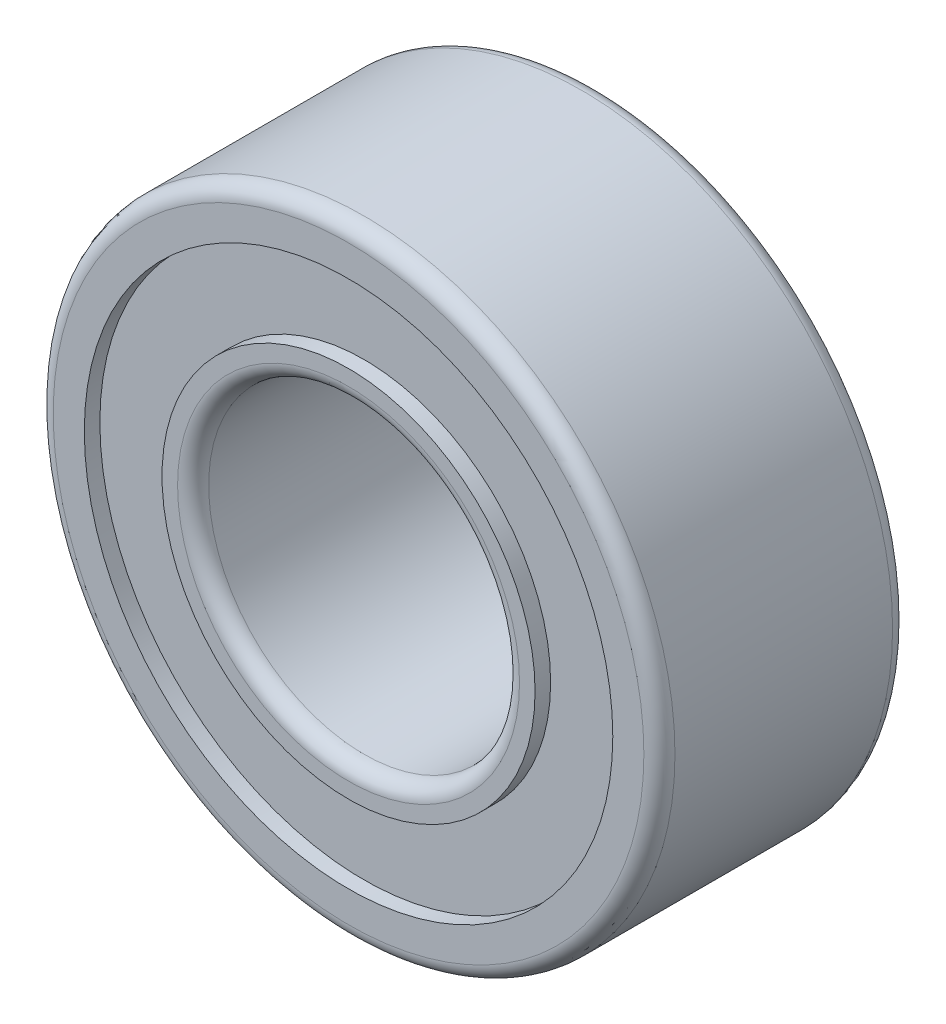
from build123d import *

# Parameters (mm, degrees)
SKETCH1_R           = 5
SKETCH1_R_2         = 2.5
BOSS_EXTRUDE1_DEPTH = 4
FILLET1_R           = 0.25
FILLET2_R           = 0.25
SKETCH2_R           = 4.25
SKETCH2_R_2         = 3
CUT_EXTRUDE1_DEPTH  = 0.25
SKETCH3_R           = 4.25
SKETCH3_R_2         = 3
CUT_EXTRUDE2_DEPTH  = 0.25


with BuildPart() as part:
    # Sketch1 → Boss-Extrude1 (new body)
    with BuildSketch(Plane.XY):
        Circle(SKETCH1_R)
        Circle(SKETCH1_R_2, mode=Mode.SUBTRACT)
    extrude(amount=BOSS_EXTRUDE1_DEPTH)

    # Fillet1
    fillet1_edges = [part.edges().sort_by_distance(p)[0] for p in [
        (-5, 0, 0),
        (-5, 0, 4),
    ]]
    fillet(fillet1_edges, radius=FILLET1_R)

    # Fillet2
    fillet2_edges = [part.edges().sort_by_distance(p)[0] for p in [
        (-2.5, 0, 0),
        (-2.5, 0, 4),
    ]]
    fillet(fillet2_edges, radius=FILLET2_R)

    # Sketch2 → Cut-Extrude1 (cut)
    with BuildSketch(Plane.XY.offset(4)):
        Circle(SKETCH2_R)
        Circle(SKETCH2_R_2, mode=Mode.SUBTRACT)
    extrude(amount=-CUT_EXTRUDE1_DEPTH, mode=Mode.SUBTRACT)

    # Sketch3 → Cut-Extrude2 (cut)
    with BuildSketch(Plane(origin=(0, 0, 0), x_dir=(-1, 0, 0), z_dir=(0, 0, -1))):
        Circle(SKETCH3_R)
        Circle(SKETCH3_R_2, mode=Mode.SUBTRACT)
    extrude(amount=-CUT_EXTRUDE2_DEPTH, mode=Mode.SUBTRACT)


solid = part.part
